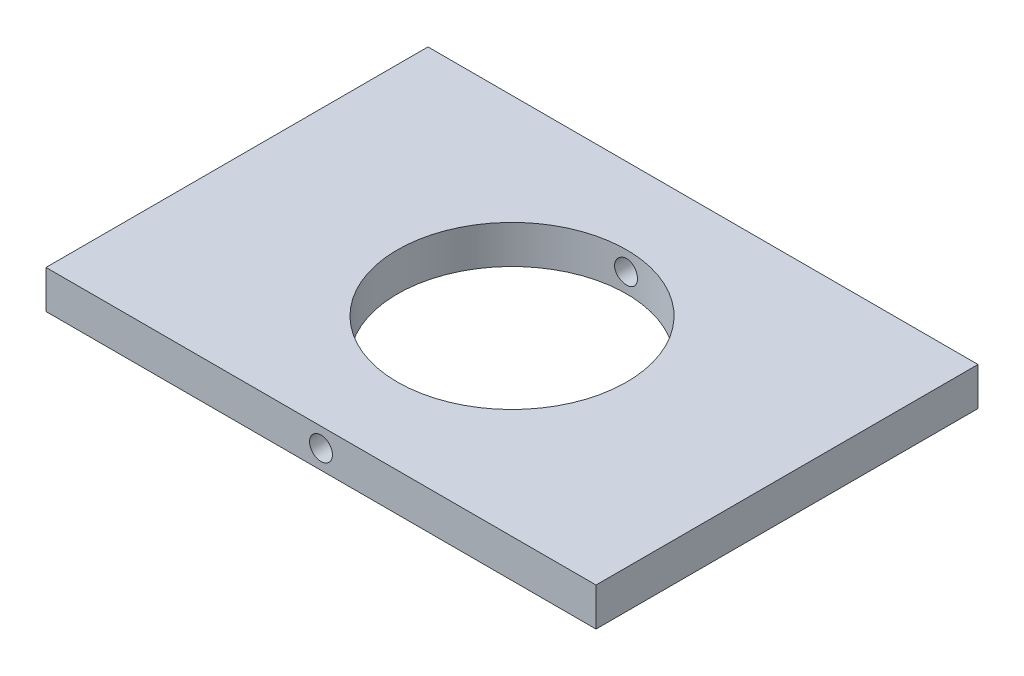
from build123d import *

# Parameters (mm, degrees)
ESQUISSE1_W             = 72
ESQUISSE1_H             = 5
BOSS_EXTRU_1_DEPTH      = 50
ESQUISSE2_R             = 15
ENL_V_MAT_EXTRU_1_DEPTH = 6
ESQUISSE5_R             = 1.5
ENL_V_MAT_EXTRU_4_DEPTH = 51


with BuildPart() as part:
    # Esquisse1 → Boss.-Extru.1 (new body)
    with BuildSketch(Plane.XY):
        with Locations((16.5, -47.5)):
            Rectangle(ESQUISSE1_W, ESQUISSE1_H)
    extrude(amount=BOSS_EXTRU_1_DEPTH)

    # Esquisse2 → Enlèv. mat.-Extru.1 (cut, through all)
    with BuildSketch(Plane(origin=(0, -45, 0), x_dir=(-1, 0, 0), z_dir=(0, 1, 0))):
        with Locations((-16.5, 25)):
            Circle(ESQUISSE2_R)
    extrude(amount=-ENL_V_MAT_EXTRU_1_DEPTH, mode=Mode.SUBTRACT)

    # Esquisse5 → Enlèv. mat.-Extru.4 (cut, through all)
    with BuildSketch(Plane.XY.offset(50)):
        with Locations((16.5, -47.5)):
            Circle(ESQUISSE5_R)
    extrude(amount=-ENL_V_MAT_EXTRU_4_DEPTH, mode=Mode.SUBTRACT)


solid = part.part
